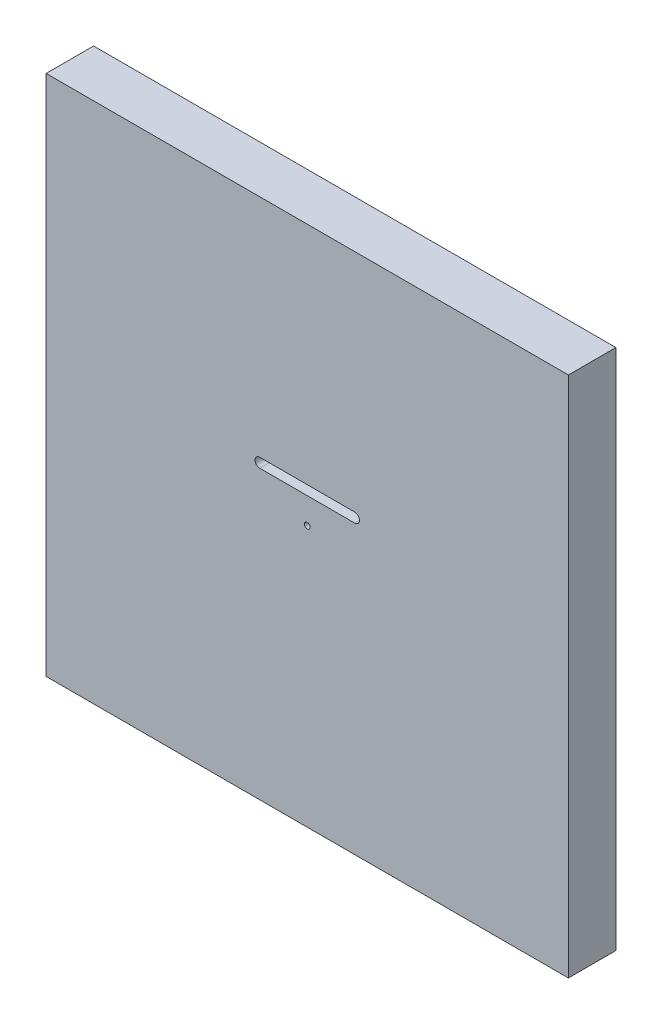
from build123d import *

# Parameters (mm, degrees)
CROQUIS1_W              = 550
CROQUIS1_H              = 550
SALIENTE_EXTRUIR1_DEPTH = 50
CROQUIS2_R              = 3
CORTAR_EXTRUIR1_DEPTH   = 50


with BuildPart() as part:
    # Croquis1 → Saliente-Extruir1 (new body)
    with BuildSketch(Plane.XY):
        with Locations((40.988720017, -96.414342629)):
            Rectangle(CROQUIS1_W, CROQUIS1_H)
    extrude(amount=SALIENTE_EXTRUIR1_DEPTH)

    # Croquis2 → Cortar-Extruir1 (cut)
    with BuildSketch(Plane(origin=(0, 0, 0), x_dir=(-1, 0, 0), z_dir=(0, 0, -1))):
        with Locations((-40.988720017, -96.414342629)):
            Circle(CROQUIS2_R)
        with BuildLine():
            Line((-90.988720017, -58.999514309), (9.011279983, -58.999514309))
            ThreePointArc((9.011279983, -58.999514309), (14.011279983, -63.999514309), (9.011279983, -68.999514309))
            Line((9.011279983, -68.999514309), (-90.988720017, -68.999514309))
            ThreePointArc((-90.988720017, -68.999514309), (-95.988720017, -63.999514309), (-90.988720017, -58.999514309))
        make_face()
    extrude(amount=-CORTAR_EXTRUIR1_DEPTH, mode=Mode.SUBTRACT)


solid = part.part
